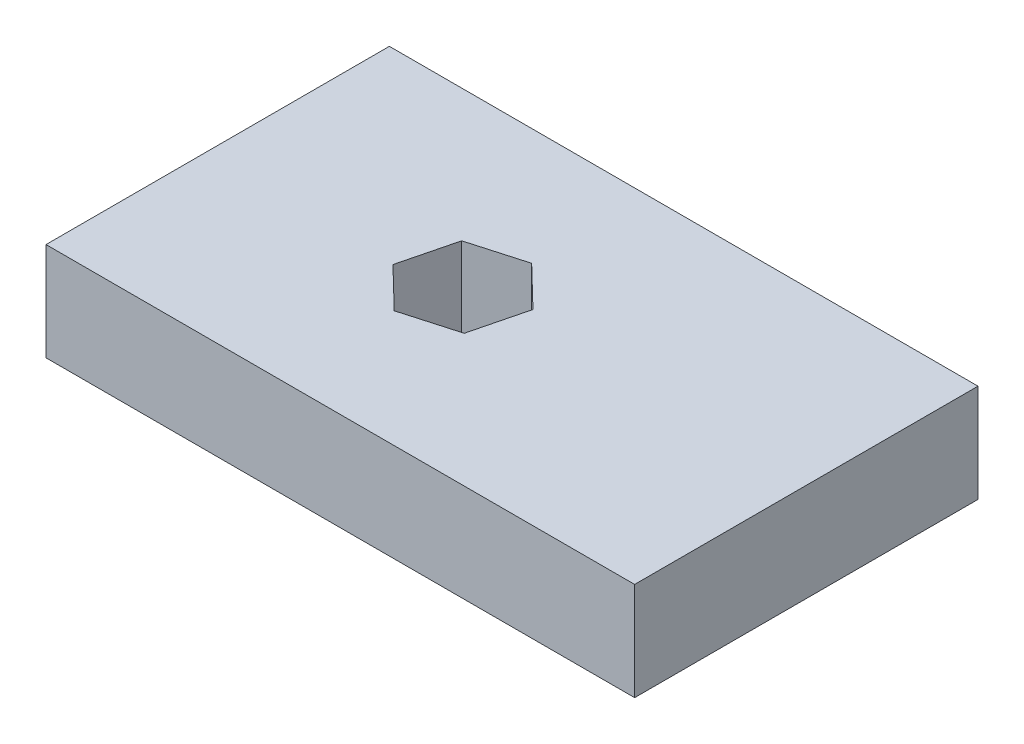
from build123d import *

# Parameters (mm, degrees)
SKETCH1_W           = 76.2
SKETCH1_H           = 44.45
BOSS_EXTRUDE1_DEPTH = 12.7
CUT_EXTRUDE1_DEPTH  = 19.558


with BuildPart() as part:
    # Sketch1 → Boss-Extrude1 (new body)
    with BuildSketch(Plane(origin=(0, 0, 0), x_dir=(1, 0, 0), z_dir=(0, 1, 0))):
        with Locations((8.71640895, -6.11057377)):
            Rectangle(SKETCH1_W, SKETCH1_H)
    extrude(amount=BOSS_EXTRUDE1_DEPTH)

    # Sketch2 → Cut-Extrude1 (cut)
    with BuildSketch(Plane(origin=(0, 12.7, 0), x_dir=(1, 0, 0), z_dir=(0, 1, 0))):
        Polygon((4.149809178, 1.001586025), (-2.901201995, -1.01002397), (-4.684602223, -8.122183766), (0.583008722, -13.222733566), (7.634019895, -11.211123571), (9.417420123, -4.098963775), align=None)
    extrude(amount=-CUT_EXTRUDE1_DEPTH, mode=Mode.SUBTRACT)


solid = part.part
